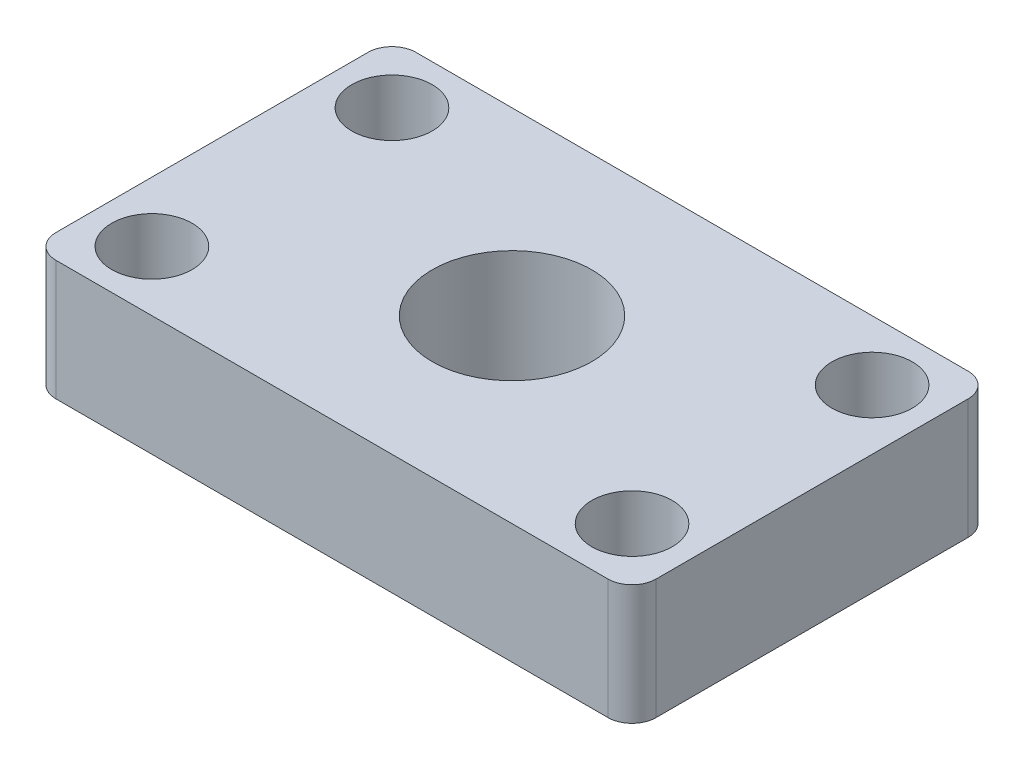
from build123d import *

# Parameters (mm, degrees)
SKETCH1_W                 = 50
SKETCH1_H                 = 30
SKETCH1_R                 = 3.35
BOSS_EXTRUDE2_DEPTH       = 10
F_8_32_TAPPED_HOLE3_D     = 3.4544
F_8_32_TAPPED_HOLE3_DEPTH = 5
F_8_32_TAPPED_HOLE3_TIP   = 1.037806461
FILLET3_R                 = 2
FILLET4_R                 = 2
F_0_535_40_TAPPED_HOLE2_D = 13.2842


with BuildPart() as part:
    # Sketch1 → Boss-Extrude2 (new body)
    with BuildSketch(Plane(origin=(0, 0, 0), x_dir=(1, 0, 0), z_dir=(0, 1, 0))):
        Rectangle(SKETCH1_W, SKETCH1_H)
        with Locations((-20, 10)):
            Circle(SKETCH1_R, mode=Mode.SUBTRACT)
        with Locations((20, 10)):
            Circle(SKETCH1_R, mode=Mode.SUBTRACT)
        with Locations((-20, -10)):
            Circle(SKETCH1_R, mode=Mode.SUBTRACT)
        with Locations((20, -10)):
            Circle(SKETCH1_R, mode=Mode.SUBTRACT)
    extrude(amount=BOSS_EXTRUDE2_DEPTH)

    # #8-32 Tapped Hole3
    with Locations(Plane(origin=(0, 5, -15), x_dir=(-1, 0, 0), z_dir=(0, 0, -1))):
        with Locations((0, 0)):
            Hole(F_8_32_TAPPED_HOLE3_D / 2, depth=F_8_32_TAPPED_HOLE3_DEPTH)
            with Locations((0, 0, -(F_8_32_TAPPED_HOLE3_DEPTH + F_8_32_TAPPED_HOLE3_TIP / 2))):  # 118° drill point
                Cone(0, F_8_32_TAPPED_HOLE3_D / 2, F_8_32_TAPPED_HOLE3_TIP, mode=Mode.SUBTRACT)

    # Fillet3
    fillet3_edges = [part.edges().sort_by_distance(p)[0] for p in [
        (25, 5, 15),
        (-25, 5, -15),
        (25, 5, -15),
    ]]
    fillet(fillet3_edges, radius=FILLET3_R)

    # Fillet4
    fillet4_edges = [part.edges().sort_by_distance(p)[0] for p in [
        (-25, 5, 15),
    ]]
    fillet(fillet4_edges, radius=FILLET4_R)

    # 0.535-40 Tapped Hole2 (through all)
    with Locations(Plane.ZX.offset(10)):
        with Locations((0, 0)):
            Hole(F_0_535_40_TAPPED_HOLE2_D / 2)


solid = part.part
